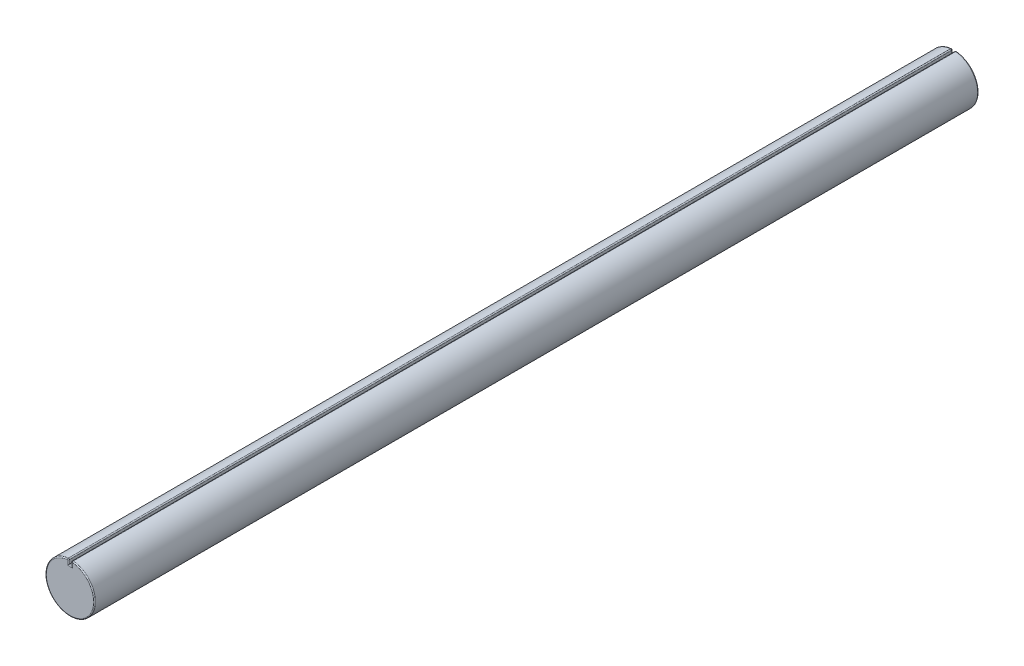
from build123d import *

# Parameters (mm, degrees)
SKETCH1_R               = 25
BOSS_EXTRUDE1_DEPTH     = 900
SKETCH2_W               = 3
SKETCH2_H               = 10
CUT_EXTRUDE1_DEPTH      = 1
CUT_EXTRUDE1_DEPTH_BACK = 901
FILLET1_R               = 1


with BuildPart() as part:
    # Sketch1 → Boss-Extrude1 (new body)
    with BuildSketch(Plane.XY):
        Circle(SKETCH1_R)
    extrude(amount=BOSS_EXTRUDE1_DEPTH)

    # Sketch2 → Cut-Extrude1 (cut, two sides)
    with BuildSketch(Plane.XY.offset(900)) as cut_extrude1_sk:
        with Locations((0, 25)):
            Rectangle(SKETCH2_W, SKETCH2_H)
    extrude(amount=CUT_EXTRUDE1_DEPTH, mode=Mode.SUBTRACT)
    extrude(cut_extrude1_sk.sketch, amount=-CUT_EXTRUDE1_DEPTH_BACK, mode=Mode.SUBTRACT)

    # Fillet1
    fillet1_edges = [part.edges().sort_by_distance(p)[0] for p in [
        (1.5, 22.477479713, 900),
        (0, 20, 0),
        (-1.5, 22.477479713, 900),
        (-17.139136501, -18.200274723, 0),
        (-1.5, 22.477479713, 0),
        (-17.139136501, -18.200274723, 900),
        (1.5, 22.477479713, 0),
        (1.5, 24.954959427, 450),
        (0, 20, 900),
        (-1.5, 24.954959427, 450),
    ]]
    fillet(fillet1_edges, radius=FILLET1_R)


solid = part.part
